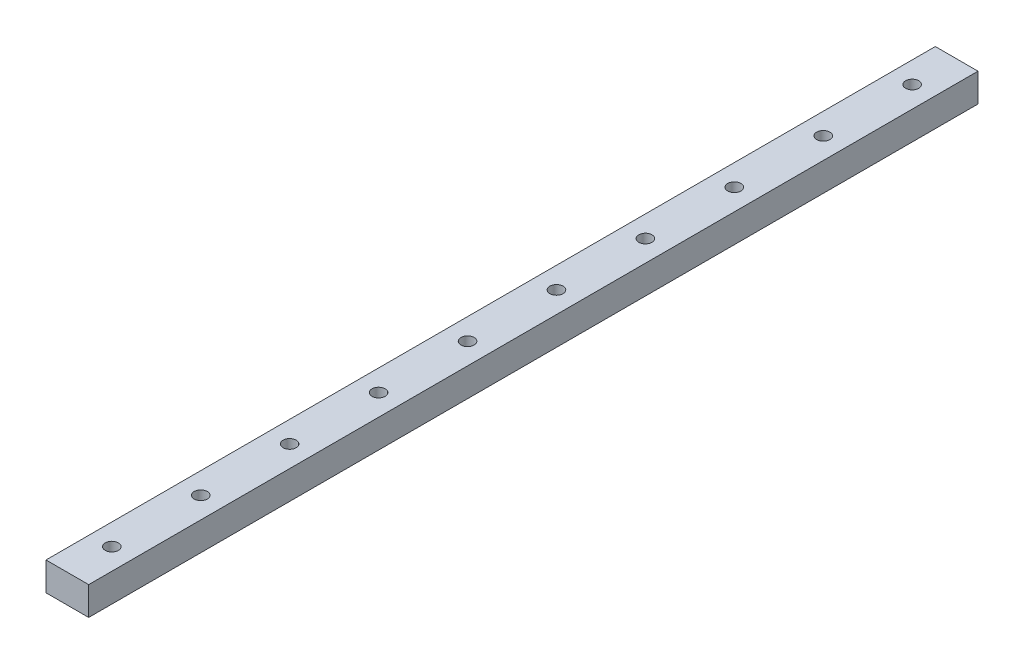
from build123d import *

# Parameters (mm, degrees)
SKETCH3_W           = 12
SKETCH3_H           = 8
BOSS_EXTRUDE1_DEPTH = 250
SKETCH4_R           = 1.85
CUT_EXTRUDE1_DEPTH  = 8
LPATTERN1_COUNT     = 10
LPATTERN1_PITCH     = 25


with BuildPart() as part:
    # Sketch3 → Boss-Extrude1 (new body)
    with BuildSketch(Plane.XY):
        with Locations((6, 4)):
            Rectangle(SKETCH3_W, SKETCH3_H)
    extrude(amount=BOSS_EXTRUDE1_DEPTH)

    # Sketch4 → Cut-Extrude1 (cut)
    with BuildSketch(Plane(origin=(0, 8, 0), x_dir=(1, 0, 0), z_dir=(0, 1, 0))):
        with Locations((6, -237.5)):
            Circle(SKETCH4_R)
    cut_extrude1 = extrude(amount=-CUT_EXTRUDE1_DEPTH, mode=Mode.SUBTRACT)

    # LPattern1: Cut-Extrude1 ×10
    with Locations(*[(0, 0, -i * LPATTERN1_PITCH) for i in range(1, LPATTERN1_COUNT)]):
        add(cut_extrude1, mode=Mode.SUBTRACT)


solid = part.part
